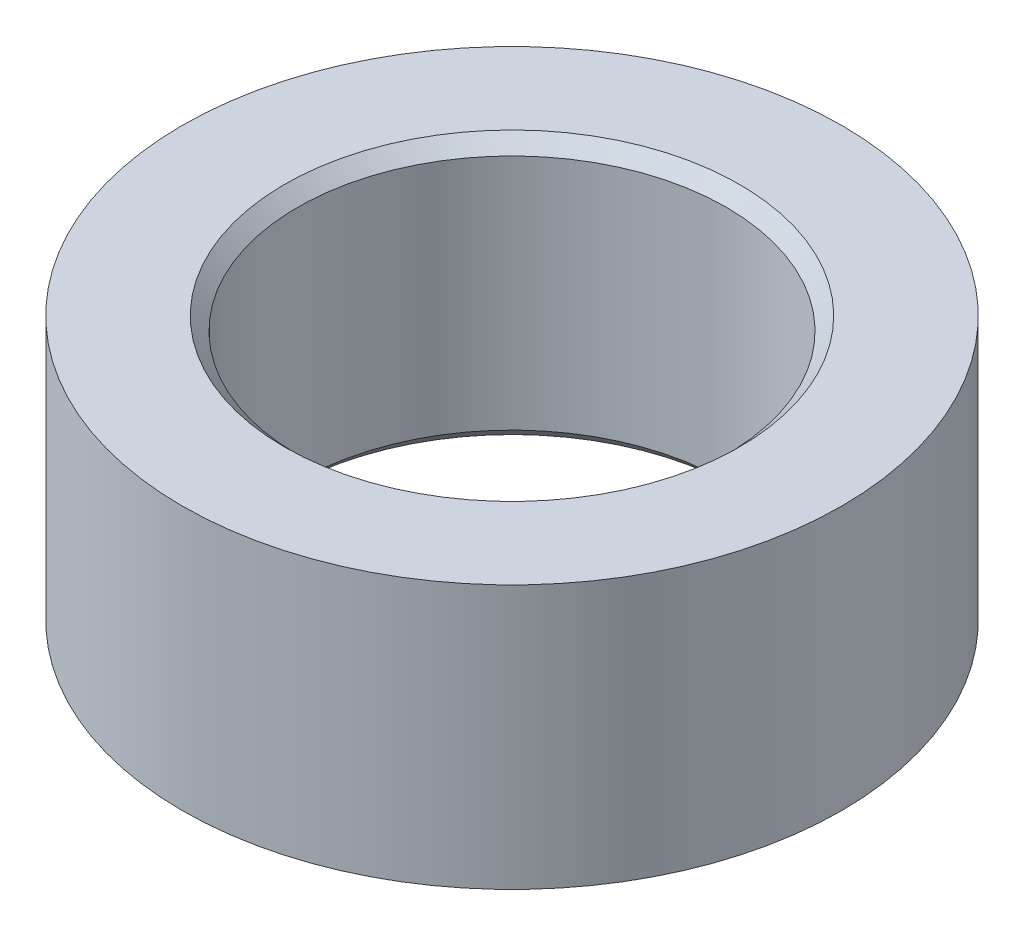
from build123d import *

# Parameters (mm, degrees)
SKETCH1_R           = 6.35
SKETCH1_R_2         = 4.1275
BOSS_EXTRUDE1_DEPTH = 5.08
CHAMFER1_SIZE       = 0.254


with BuildPart() as part:
    # Sketch1 → Boss-Extrude1 (new body)
    with BuildSketch(Plane(origin=(0, 0, 0), x_dir=(1, 0, 0), z_dir=(0, 1, 0))):
        Circle(SKETCH1_R)
        Circle(SKETCH1_R_2, mode=Mode.SUBTRACT)
    extrude(amount=BOSS_EXTRUDE1_DEPTH)

    # Chamfer1
    chamfer1_edges = [part.edges().sort_by_distance(p)[0] for p in [
        (-4.1275, 0, 0),
        (-4.1275, 5.08, 0),
    ]]
    chamfer(chamfer1_edges, length=CHAMFER1_SIZE)


solid = part.part
